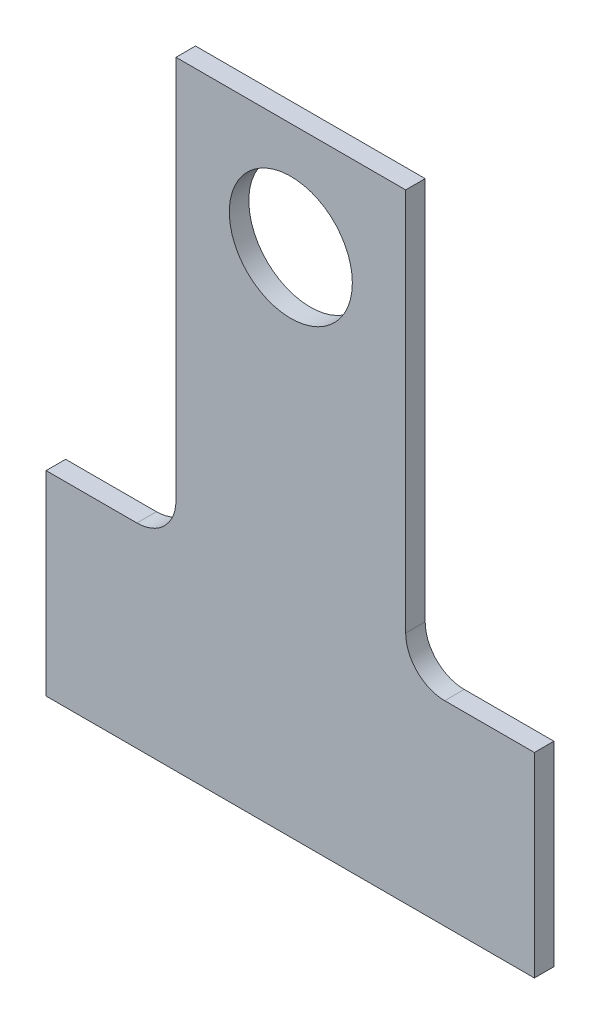
from build123d import *

# Parameters (mm, degrees)
DODANIE_WYCI_GNI_CIE1_DEPTH = 1
SZKIC2_R                    = 3.15
WYTNIJ_WYCI_GNI_CIE1_DEPTH  = 1


with BuildPart() as part:
    # Szkic1 → Dodanie-wyciągnięcie1 (new body)
    with BuildSketch(Plane.XY):
        with BuildLine():
            Line((-12.5, -6), (-12.5, -16))
            Line((-12.5, -16), (12.5, -16))
            Line((12.5, -16), (12.5, -6))
            Line((12.5, -6), (7.91, -6))
            ThreePointArc((7.91, -6), (6.495786438, -5.414213562), (5.91, -4))
            Line((5.91, -4), (5.91, 15.65))
            Line((5.91, 15.65), (-5.85, 15.65))
            Line((-5.85, 15.65), (-5.85, -4))
            ThreePointArc((-5.85, -4), (-6.435786438, -5.414213562), (-7.85, -6))
            Line((-7.85, -6), (-12.5, -6))
        make_face()
    extrude(amount=DODANIE_WYCI_GNI_CIE1_DEPTH)

    # Szkic2 → Wytnij-wyciągnięcie1 (cut)
    with BuildSketch(Plane.XY.offset(1)):
        with Locations((0.03, 10.16)):
            Circle(SZKIC2_R)
    extrude(amount=-WYTNIJ_WYCI_GNI_CIE1_DEPTH, mode=Mode.SUBTRACT)


solid = part.part
